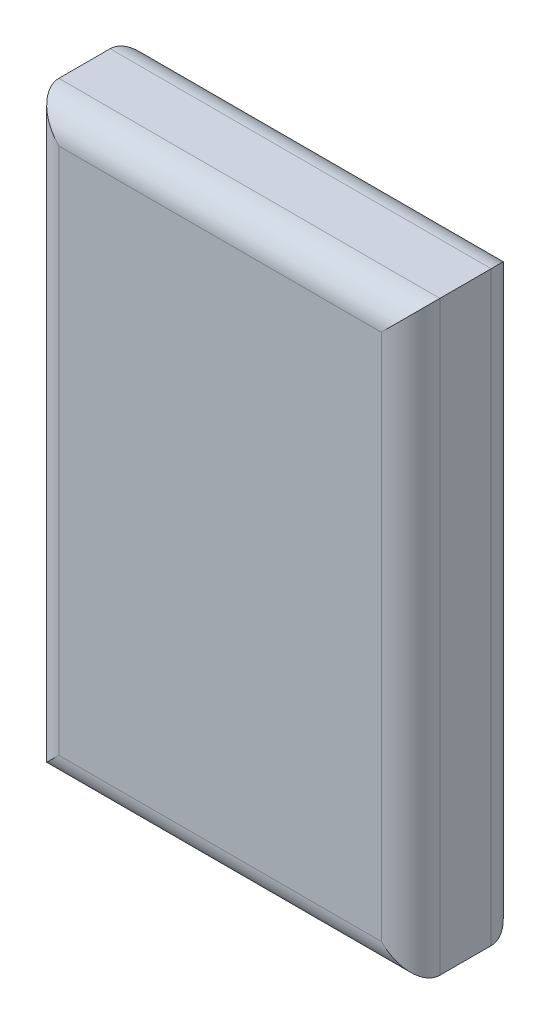
from build123d import *

# Parameters (mm, degrees)
SKETCH1_W           = 33.02
SKETCH1_H           = 50.8
BOSS_EXTRUDE1_DEPTH = 9.525
FILLET1_R           = 2.54


with BuildPart() as part:
    # Sketch1 → Boss-Extrude1 (new body)
    with BuildSketch(Plane.XY):
        Rectangle(SKETCH1_W, SKETCH1_H)
    extrude(amount=BOSS_EXTRUDE1_DEPTH)

    # Fillet1
    fillet1_edges = [part.edges().sort_by_distance(p)[0] for p in [
        (16.51, 0, 9.525),
        (0, 25.4, 9.525),
        (-16.51, 0, 9.525),
        (0, 25.4, 0),
        (16.51, 0, 0),
        (0, -25.4, 0),
        (-16.51, 0, 0),
        (0, -25.4, 9.525),
    ]]
    fillet(fillet1_edges, radius=FILLET1_R)


solid = part.part
